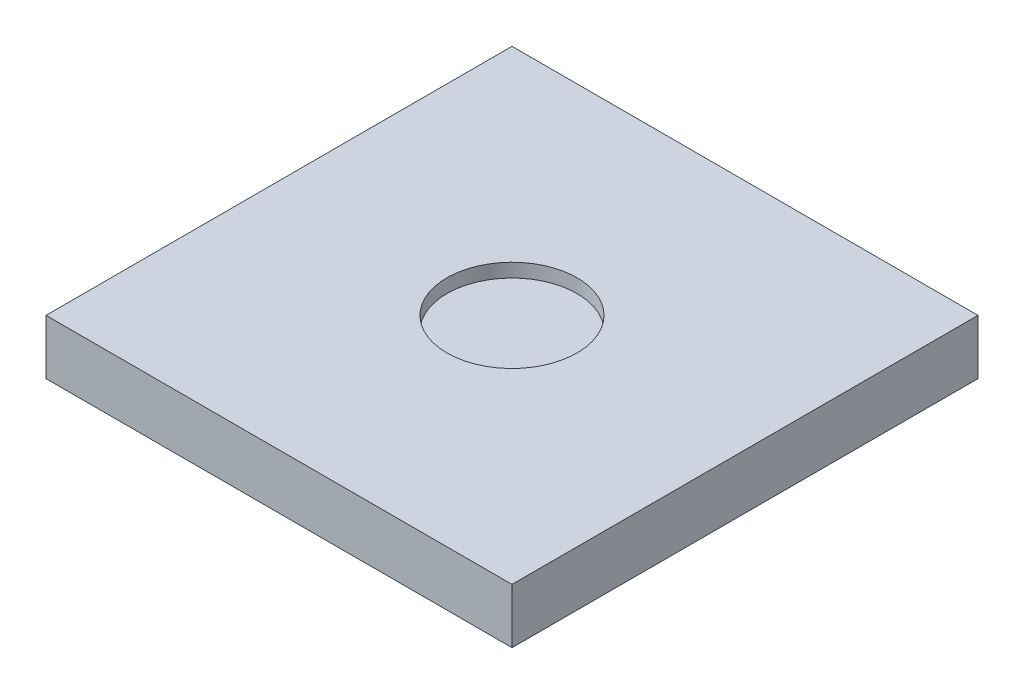
from build123d import *

# Parameters (mm, degrees)
SKETCH1_W           = 340
SKETCH1_H           = 340
BOSS_EXTRUDE1_DEPTH = 40
SKETCH2_R           = 47.5
CUT_EXTRUDE1_DEPTH  = 10


with BuildPart() as part:
    # Sketch1 → Boss-Extrude1 (new body)
    with BuildSketch(Plane(origin=(0, 0, 0), x_dir=(1, 0, 0), z_dir=(0, 1, 0))):
        Rectangle(SKETCH1_W, SKETCH1_H)
    extrude(amount=BOSS_EXTRUDE1_DEPTH)

    # Sketch2 → Cut-Extrude1 (cut)
    with BuildSketch(Plane(origin=(0, 40, 0), x_dir=(1, 0, 0), z_dir=(0, 1, 0))):
        Circle(SKETCH2_R)
    extrude(amount=-CUT_EXTRUDE1_DEPTH, mode=Mode.SUBTRACT)


solid = part.part
